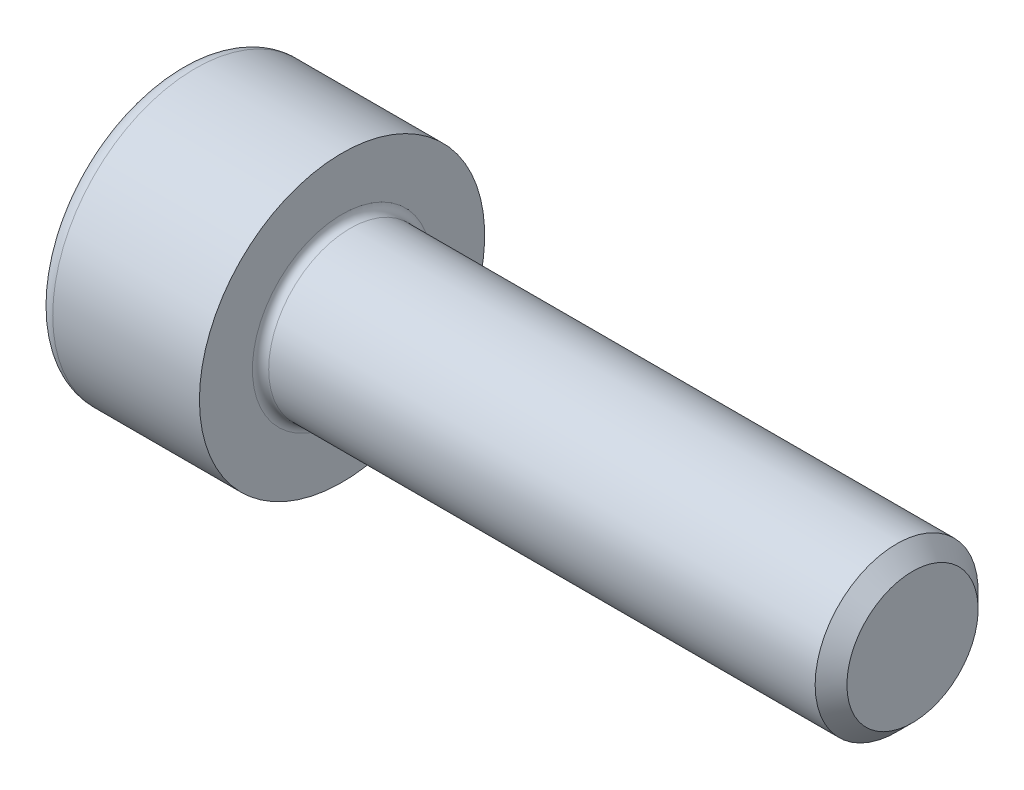
from build123d import *

# Parameters (mm, degrees)
FILLET1_R   = 0.2
FILLET2_R   = 0.4
HEX_2_DEPTH = 2


with BuildPart() as part:
    # BodySke → Base-Revolve (revolve)
    with BuildSketch(Plane.XY):
        Polygon((0, 0), (0, 3.5), (4, 3.5), (4, 2), (17.61, 2), (18, 1.61), (18, 0), align=None)
    revolve(axis=Axis((-31.75, 0, 0), (1, 0, 0)))

    # Fillet1
    fillet1_edges = [part.edges().sort_by_distance(p)[0] for p in [
        (4, -2, 0),
    ]]
    fillet(fillet1_edges, radius=FILLET1_R)

    # Fillet2
    fillet2_edges = [part.edges().sort_by_distance(p)[0] for p in [
        (0, -3.5, 0),
    ]]
    fillet(fillet2_edges, radius=FILLET2_R)

    # Sketch2 → Hex-PreBroach (revolve, cut)
    with BuildSketch(Plane.XY):
        Polygon((0, 1.51), (2, 1.51), (2.871798906, 0), (0, 0), align=None)
    revolve(axis=Axis((0, 0, 0), (1, 0, 0)), mode=Mode.SUBTRACT)

    # Sketch3 → Hex 2 (cut)
    with BuildSketch(Plane(origin=(0, 0, 0), x_dir=(0, 0.5, 0.866025404), z_dir=(-1, 0, 0))):
        Polygon((0.871798906, 1.51), (-0.871798906, 1.51), (-1.743597813, 0), (-0.871798906, -1.51), (0.871798906, -1.51), (1.743597813, 0), align=None)
    extrude(amount=-HEX_2_DEPTH, mode=Mode.SUBTRACT)


solid = part.part
